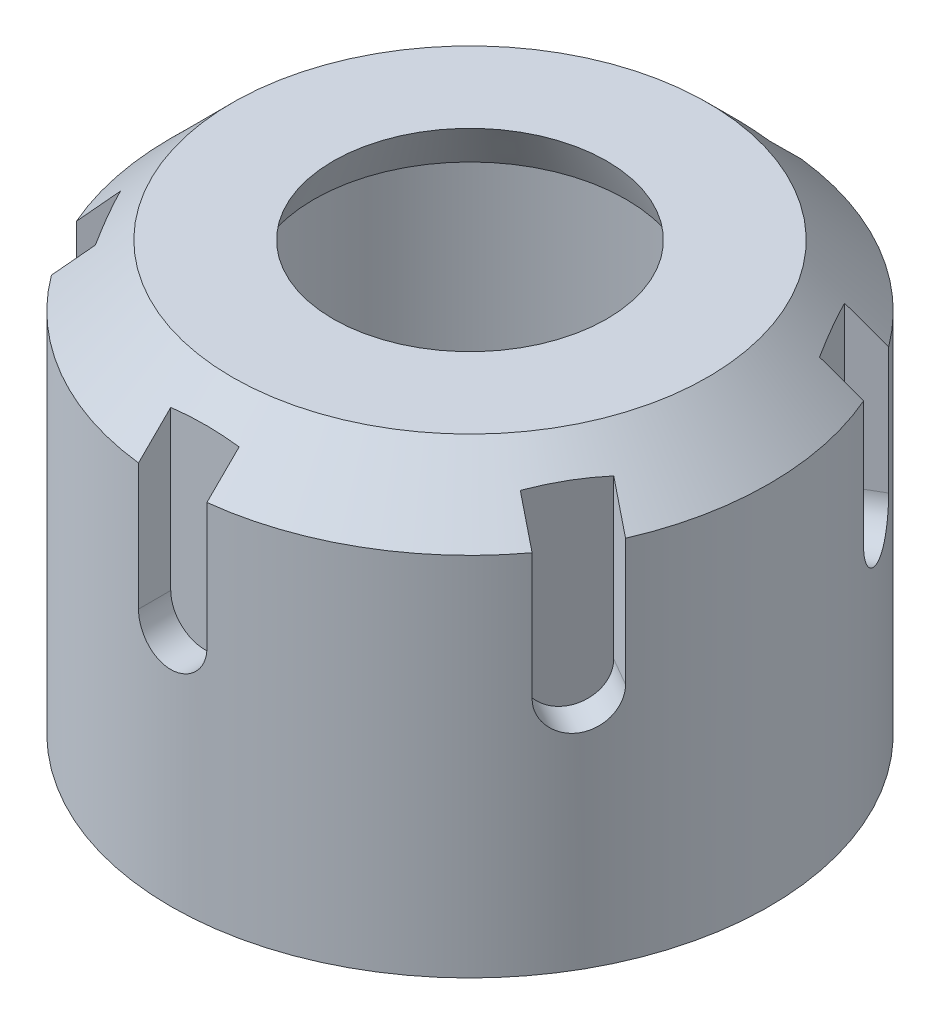
from build123d import *

# Parameters (mm, degrees)
CUT_EXTRUDE_4_DEPTH      = 9
PATTERN_CIRCULAR_1_COUNT = 6


with BuildPart() as part:
    # 草图1 → 旋转1 (revolve)
    with BuildSketch(Plane.XY):
        Polygon((-16, 52.038271605), (-27.803703704, 52.038271605), (-35, 44.841975309), (-35, 2.038271605), (-30, 2.038271605), (-30, 42.770907497), (-25.732635892, 47.038271605), (-18.250236606, 47.038271605), align=None)
    revolve(axis=Axis((0, 88.586419753, 0), (0, -1, 0)))

    # 草图2 → 切除-拉伸4 (cut)
    with BuildSketch(Plane.XY.offset(40)):
        with BuildLine():
            Line((-4, 52.038271605), (-4, 30.038271605))
            ThreePointArc((-4, 30.038271605), (0, 26.038271605), (4, 30.038271605))
            Line((4, 30.038271605), (4, 52.038271605))
            Line((4, 52.038271605), (-4, 52.038271605))
        make_face()
    cut_extrude_4 = extrude(amount=-CUT_EXTRUDE_4_DEPTH, mode=Mode.SUBTRACT)

    # 阵列(圆周)1: 切除-拉伸4 ×6 about axis
    pattern_circular_1_axis = Axis((0, 0, 0), (0, 1, 0))
    for i in range(1, PATTERN_CIRCULAR_1_COUNT):
        add(cut_extrude_4.rotate(pattern_circular_1_axis, i * 360 / PATTERN_CIRCULAR_1_COUNT), mode=Mode.SUBTRACT)


solid = part.part
